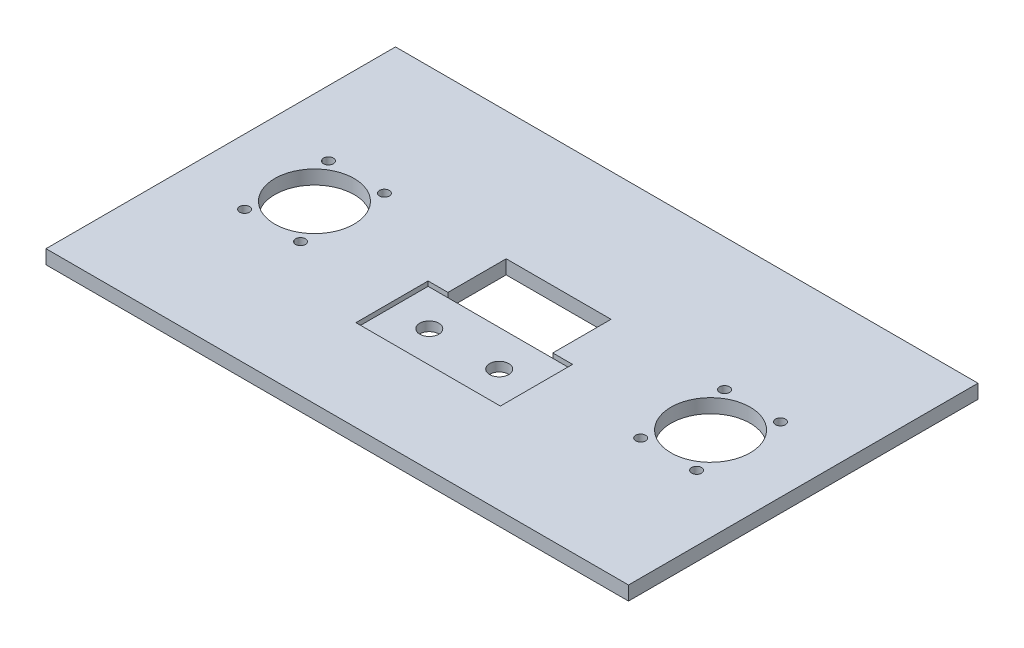
from build123d import *

# Parameters (mm, degrees)
SKETCH1_W           = 250
SKETCH1_H           = 150
SKETCH1_R           = 4.1
BOSS_EXTRUDE1_DEPTH = 6
SKETCH2_W           = 62
SKETCH2_H           = 31
CUT_EXTRUDE1_DEPTH  = 2
SKETCH3_R           = 17
SKETCH3_R_2         = 2.125
CUT_EXTRUDE3_DEPTH  = 29


with BuildPart() as part:
    # Sketch1 → Boss-Extrude1 (new body)
    with BuildSketch(Plane(origin=(0, 0, 0), x_dir=(1, 0, 0), z_dir=(0, 1, 0))):
        Rectangle(SKETCH1_W, SKETCH1_H)
        with Locations((15, -20.5)):
            Circle(SKETCH1_R, mode=Mode.SUBTRACT)
        with Locations((-15, -20.5)):
            Circle(SKETCH1_R, mode=Mode.SUBTRACT)
    extrude(amount=BOSS_EXTRUDE1_DEPTH)

    # Sketch2 → Cut-Extrude1 (cut)
    with BuildSketch(Plane(origin=(0, 6, 0), x_dir=(1, 0, 0), z_dir=(0, 1, 0))):
        with Locations((0, -20.5)):
            Rectangle(SKETCH2_W, SKETCH2_H)
    extrude(amount=-CUT_EXTRUDE1_DEPTH, mode=Mode.SUBTRACT)

    # Sketch3 → Cut-Extrude3 (cut)
    with BuildSketch(Plane(origin=(0, 6, 0), x_dir=(1, 0, 0), z_dir=(0, 1, 0))):
        Polygon((22.5, 20), (-22.5, 20), (-22.5, -5), (0, -5), (22.5, -5), align=None)
        with Locations((-85, 0.222388038)):
            Circle(SKETCH3_R)
        with Locations((85, 0.222388038)):
            Circle(SKETCH3_R)
        with Locations((-97, 18.222388038)):
            Circle(SKETCH3_R_2)
        with Locations((-97, -17.777611962)):
            Circle(SKETCH3_R_2)
        with Locations((-73, -17.777611962)):
            Circle(SKETCH3_R_2)
        with Locations((-73, 18.222388038)):
            Circle(SKETCH3_R_2)
        with Locations((73, -17.777611962)):
            Circle(SKETCH3_R_2)
        with Locations((97, -17.777611962)):
            Circle(SKETCH3_R_2)
        with Locations((97, 18.222388038)):
            Circle(SKETCH3_R_2)
        with Locations((73, 18.222388038)):
            Circle(SKETCH3_R_2)
    extrude(amount=-CUT_EXTRUDE3_DEPTH, mode=Mode.SUBTRACT)


solid = part.part
